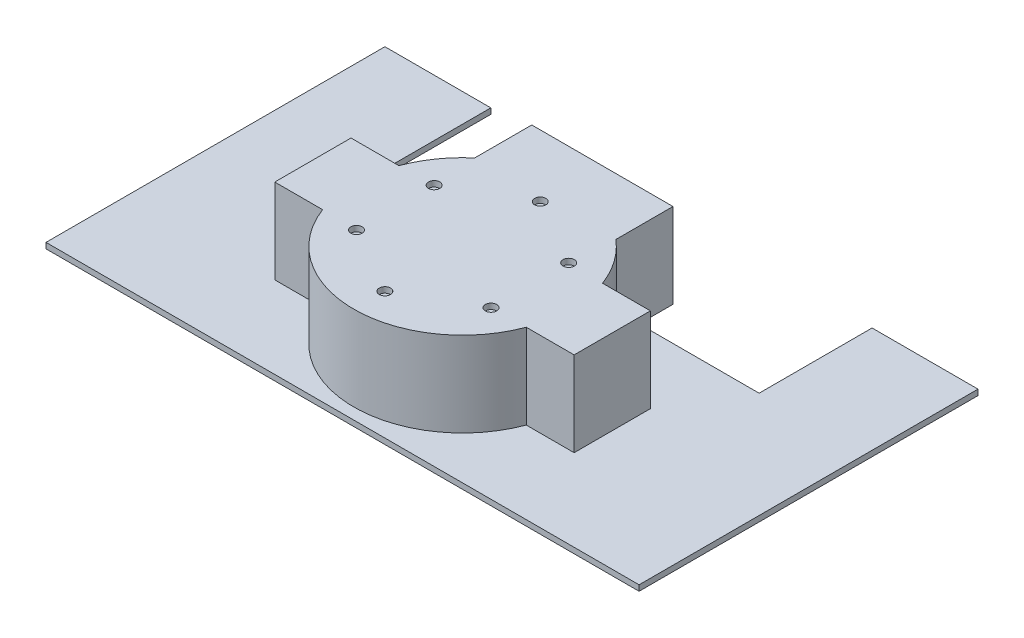
from build123d import *

# Parameters (mm, degrees)
BOSS_EXTRUDE1_DEPTH = 30
BOSS_EXTRUDE2_DEPTH = 2
SKETCH3_R           = 2
CUT_EXTRUDE1_DEPTH  = 2


with BuildPart() as part:
    # Sketch1 → Boss-Extrude1 (new body)
    with BuildSketch(Plane(origin=(0, 0, 0), x_dir=(1, 0, 0), z_dir=(0, 1, 0))):
        with BuildLine():
            Line((36.055512755, -13.5), (-36.055512755, -13.5))
            ThreePointArc((-36.055512755, -13.5), (0, -38.5), (36.055512755, -13.5))
        make_face()
        with BuildLine():
            Line((36.055512755, 13.5), (-36.055512755, 13.5))
            ThreePointArc((-36.055512755, 13.5), (-38.5, 0), (-36.055512755, -13.5))
            Line((-36.055512755, -13.5), (36.055512755, -13.5))
            ThreePointArc((36.055512755, -13.5), (37.883949379, -6.859765264), (38.5, 0))
            ThreePointArc((38.5, 0), (37.883949379, 6.859765264), (36.055512755, 13.5))
        make_face()
        with BuildLine():
            Line((-36.055512755, 13.5), (-53, 13.5))
            Line((-53, 13.5), (-53, -13.5))
            Line((-53, -13.5), (-36.055512755, -13.5))
            ThreePointArc((-36.055512755, -13.5), (-38.5, 0), (-36.055512755, 13.5))
        make_face()
        with BuildLine():
            ThreePointArc((25, 29.278831944), (0, 38.5), (-25, 29.278831944))
            Line((-25, 29.278831944), (-25, 27.5))
            Line((-25, 27.5), (25, 27.5))
            Line((25, 27.5), (25, 29.278831944))
        make_face()
        with BuildLine():
            Line((53, 13.5), (36.055512755, 13.5))
            ThreePointArc((36.055512755, 13.5), (37.883949379, 6.859765264), (38.5, 0))
            ThreePointArc((38.5, 0), (37.883949379, -6.859765264), (36.055512755, -13.5))
            Line((36.055512755, -13.5), (53, -13.5))
            Line((53, -13.5), (53, 13.5))
        make_face()
        with BuildLine():
            ThreePointArc((-25, 29.278831944), (-31.530727772, 22.092152593), (-36.055512755, 13.5))
            Line((-36.055512755, 13.5), (36.055512755, 13.5))
            ThreePointArc((36.055512755, 13.5), (31.530727772, 22.092152593), (25, 29.278831944))
            Line((25, 29.278831944), (25, 27.5))
            Line((25, 27.5), (-25, 27.5))
            Line((-25, 27.5), (-25, 29.278831944))
        make_face()
        with BuildLine():
            Line((-25, 49.5), (-25, 29.278831944))
            ThreePointArc((-25, 29.278831944), (0, 38.5), (25, 29.278831944))
            Line((25, 29.278831944), (25, 49.5))
            Line((25, 49.5), (-25, 49.5))
        make_face()
    extrude(amount=BOSS_EXTRUDE1_DEPTH)

    # Sketch3 → Cut-Extrude1 (cut)
    with BuildSketch(Plane(origin=(0, 30, 0), x_dir=(1, 0, 0), z_dir=(0, 1, 0))):
        with Locations((0, 27.5)):
            Circle(SKETCH3_R)
        with Locations((23.815698604, 13.75)):
            Circle(SKETCH3_R)
        with Locations((23.815698604, -13.75)):
            Circle(SKETCH3_R)
        with Locations((0, -27.5)):
            Circle(SKETCH3_R)
        with Locations((-23.815698604, -13.75)):
            Circle(SKETCH3_R)
        with Locations((-23.815698604, 13.75)):
            Circle(SKETCH3_R)
    extrude(amount=-CUT_EXTRUDE1_DEPTH, mode=Mode.SUBTRACT)


with BuildPart() as body_2:
    # Sketch2 → Boss-Extrude2 (new body)
    with BuildSketch(Plane(origin=(0, 0, 0), x_dir=(-1, 0, 0), z_dir=(0, -1, 0))):
        with BuildLine():
            Line((-105, -42.5), (105, -42.5))
            Line((105, -42.5), (105, 77.5))
            Line((105, 77.5), (67.5, 77.5))
            Line((67.5, 77.5), (67.5, 37.5))
            Line((67.5, 37.5), (25, 37.5))
            Line((25, 37.5), (25, 29.278831944))
            ThreePointArc((25, 29.278831944), (31.530727772, 22.092152593), (36.055512755, 13.5))
            Line((36.055512755, 13.5), (53, 13.5))
            Line((53, 13.5), (53, -13.5))
            Line((53, -13.5), (36.055512755, -13.5))
            ThreePointArc((36.055512755, -13.5), (0, -38.5), (-36.055512755, -13.5))
            Line((-36.055512755, -13.5), (-53, -13.5))
            Line((-53, -13.5), (-53, 13.5))
            Line((-53, 13.5), (-36.055512755, 13.5))
            ThreePointArc((-36.055512755, 13.5), (-31.530727772, 22.092152593), (-25, 29.278831944))
            Line((-25, 29.278831944), (-25, 37.5))
            Line((-25, 37.5), (-67.5, 37.5))
            Line((-67.5, 37.5), (-67.5, 77.5))
            Line((-67.5, 77.5), (-105, 77.5))
            Line((-105, 77.5), (-105, -42.5))
        make_face()
    extrude(amount=BOSS_EXTRUDE2_DEPTH)


solid = Compound([part.part, body_2.part])
